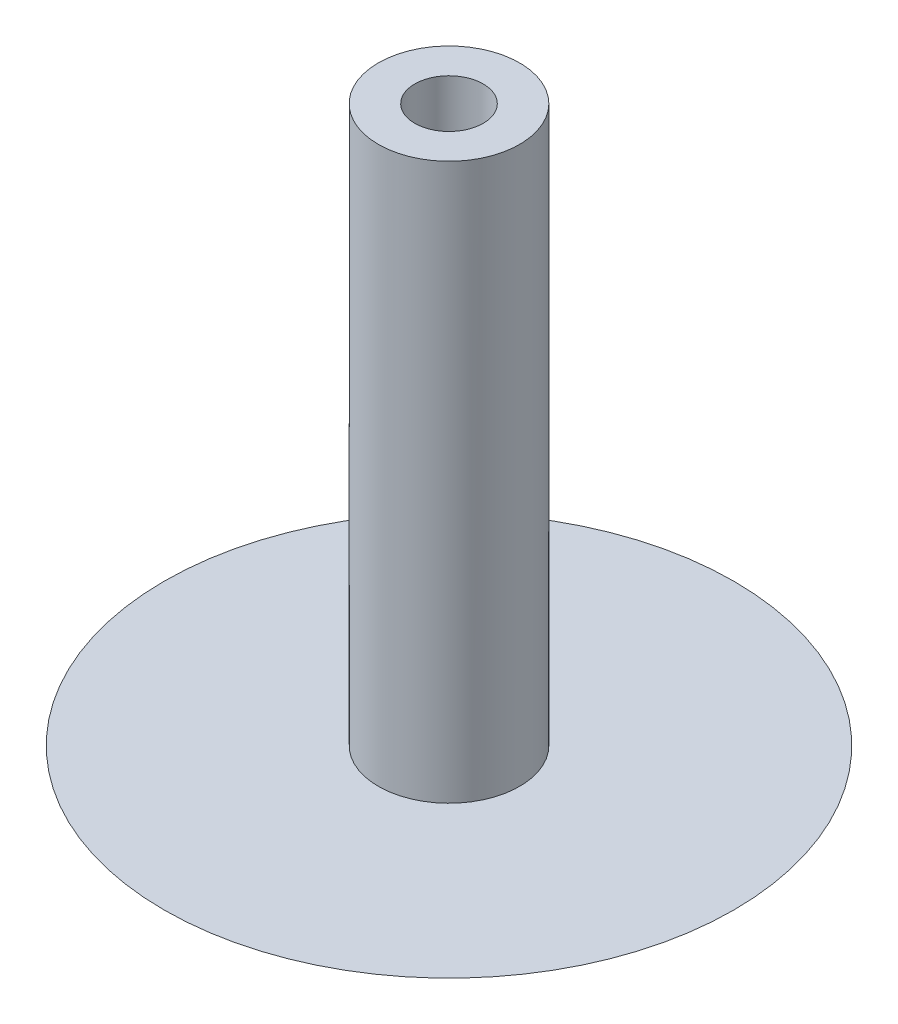
from build123d import *

# Parameters (mm, degrees)
SKETCH1_R           = 1.9685
SKETCH1_R_2         = 0.9525
BOSS_EXTRUDE1_DEPTH = 15.494


with BuildPart() as part:
    # Sketch1 → Boss-Extrude1 (new body)
    with BuildSketch(Plane(origin=(0, 0, 0), x_dir=(1, 0, 0), z_dir=(0, 1, 0))):
        Circle(SKETCH1_R)
        Circle(SKETCH1_R_2, mode=Mode.SUBTRACT)
    extrude(amount=BOSS_EXTRUDE1_DEPTH)

    # Sketch2 one side → Revolve1 (revolve)
    with BuildSketch(Plane.XY):
        with BuildLine():
            ThreePointArc((0, -2.54), (4.166998508, -1.889526586), (7.9375, 0))
            Line((7.9375, 0), (0, 0))
            Line((0, 0), (0, -2.54))
        make_face()
    revolve(axis=Axis((0, 0, 0), (0, -1, 0)))


solid = part.part
